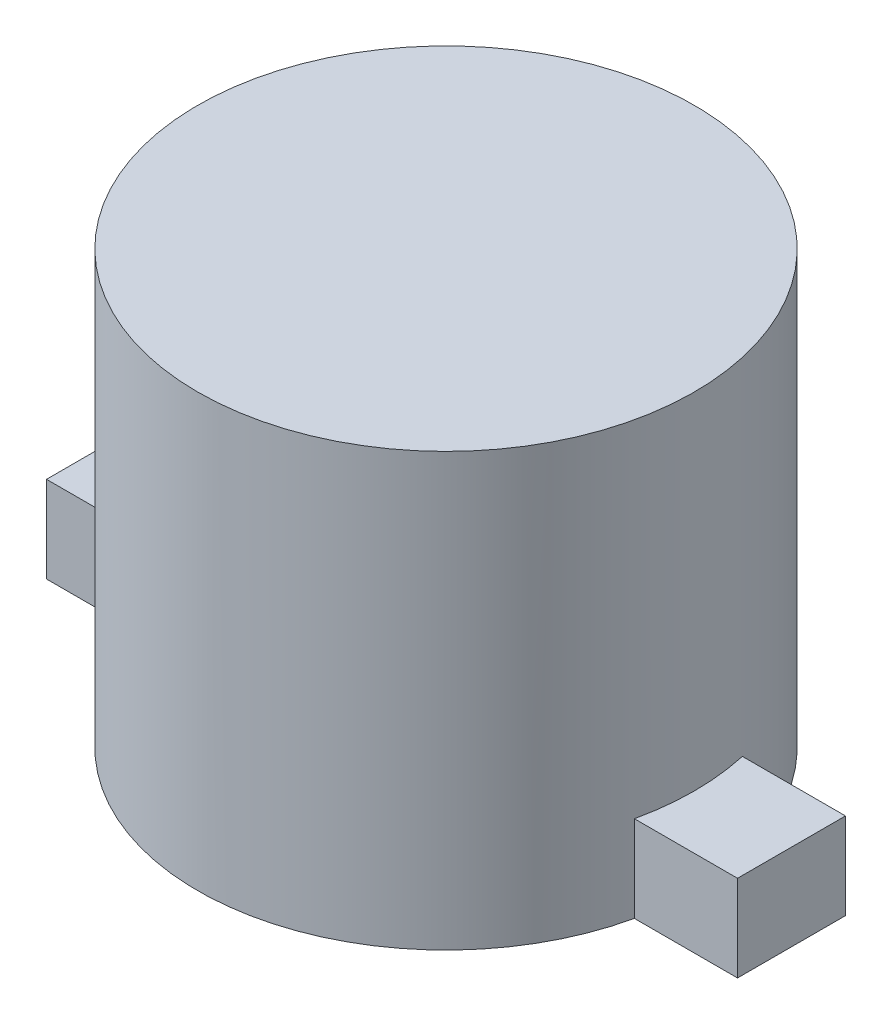
from build123d import *

# Parameters (mm, degrees)
SKETCH1_R           = 5.75
BOSS_EXTRUDE1_DEPTH = 10
SKETCH2_W           = 16
SKETCH2_H           = 2.5
BOSS_EXTRUDE2_DEPTH = 2


with BuildPart() as part:
    # Sketch1 → Boss-Extrude1 (new body)
    with BuildSketch(Plane(origin=(0, 0, 0), x_dir=(1, 0, 0), z_dir=(0, 1, 0))):
        Circle(SKETCH1_R)
    extrude(amount=BOSS_EXTRUDE1_DEPTH)

    # Sketch2 → Boss-Extrude2 (add)
    with BuildSketch(Plane(origin=(0, 0, 0), x_dir=(-1, 0, 0), z_dir=(0, -1, 0))):
        Rectangle(SKETCH2_W, SKETCH2_H)
    extrude(amount=-BOSS_EXTRUDE2_DEPTH)


solid = part.part
